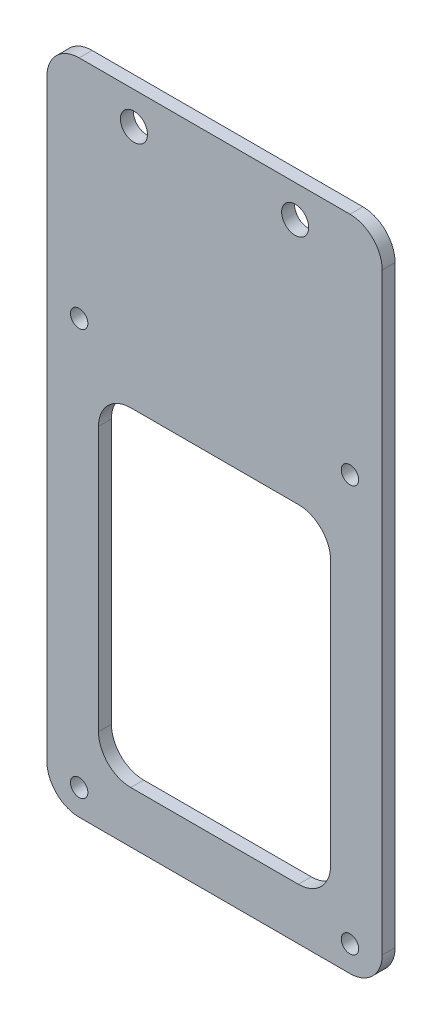
from build123d import *

# Parameters (mm, degrees)
SKETCH_1_W          = 52
SKETCH_1_H          = 102
EXTRUDE_1_DEPTH     = 2
FILLET_1_R          = 5
SKETCH_2_R          = 2.1
SKETCH_2_R_2        = 1.35
CUT_EXTRUDE_1_DEPTH = 3
SKETCH_3_W          = 36
SKETCH_3_H          = 51
CUT_EXTRUDE_2_DEPTH = 10
FILLET_2_R          = 5


with BuildPart() as part:
    # 草图1 → 凸台-拉伸1 (new body)
    with BuildSketch(Plane.XY):
        Rectangle(SKETCH_1_W, SKETCH_1_H)
    extrude(amount=EXTRUDE_1_DEPTH)

    # 圆角1
    fillet_1_edges = [part.edges().sort_by_distance(p)[0] for p in [
        (26, -51, 1),
        (-26, -51, 1),
        (-26, 51, 1),
        (26, 51, 1),
    ]]
    fillet(fillet_1_edges, radius=FILLET_1_R)

    # 草图2 → 切除-拉伸1 (cut, through all)
    with BuildSketch(Plane.XY.offset(2)):
        with Locations((-12.5, 46)):
            Circle(SKETCH_2_R)
        with Locations((12.5, 46)):
            Circle(SKETCH_2_R)
        with Locations((-21, 16)):
            Circle(SKETCH_2_R_2)
        with Locations((21, 16)):
            Circle(SKETCH_2_R_2)
        with Locations((-21, -47)):
            Circle(SKETCH_2_R_2)
        with Locations((21, -47)):
            Circle(SKETCH_2_R_2)
    extrude(amount=-CUT_EXTRUDE_1_DEPTH, mode=Mode.SUBTRACT)

    # 草图3 → 切除-拉伸2 (cut)
    with BuildSketch(Plane.XY.offset(2)):
        with Locations((0, -17.5)):
            Rectangle(SKETCH_3_W, SKETCH_3_H)
    extrude(amount=-CUT_EXTRUDE_2_DEPTH, mode=Mode.SUBTRACT)

    # 圆角2
    fillet_2_edges = [part.edges().sort_by_distance(p)[0] for p in [
        (18, 8, 1),
        (18, -43, 1),
        (-18, -43, 1),
        (-18, 8, 1),
    ]]
    fillet(fillet_2_edges, radius=FILLET_2_R)


solid = part.part
